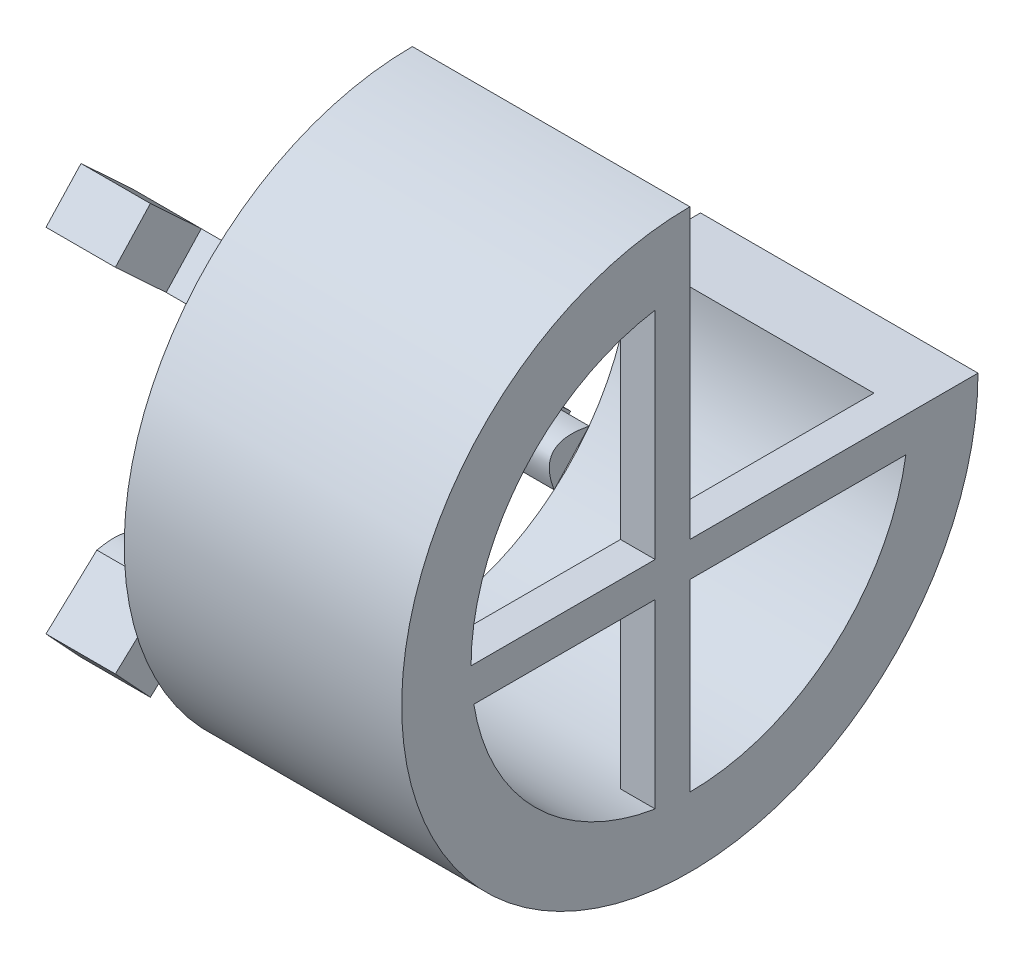
from build123d import *

# Parameters (mm, degrees)
SKETCH1_W             = 20
SKETCH1_H             = 5
REVOLVE1_ANGLE        = 270
BOSS_EXTRUDE1_DEPTH   = 2.5
BOSS_EXTRUDE2_DEPTH   = 10
BOSS_EXTRUDE2_2_DEPTH = 10
BOSS_EXTRUDE2_3_DEPTH = 10
SKETCH5_W             = 5
SKETCH5_H             = 3.710509324
BOSS_EXTRUDE3_DEPTH   = 5
SKETCH6_W             = 5
SKETCH6_H             = 3.710509324
BOSS_EXTRUDE4_DEPTH   = 5
SKETCH7_W             = 5
SKETCH7_H             = 3.710509324
BOSS_EXTRUDE5_DEPTH   = 5


with BuildPart() as part:
    # Sketch1 → Revolve1 (revolve)
    with BuildSketch(Plane.XY):
        with Locations((10, 18.27)):
            Rectangle(SKETCH1_W, SKETCH1_H)
    revolve(axis=Axis((-37.288540606, 0, 0), (1, 0, 0)), revolution_arc=REVOLVE1_ANGLE)

    # Sketch2 → Boss-Extrude1 (add)
    with BuildSketch(Plane(origin=(20, 0, 0), x_dir=(0, 0, -1), z_dir=(1, 0, 0))):
        with BuildLine():
            Line((0, 20.77), (0, -20.77))
            ThreePointArc((0, -20.77), (-1.252278215, -20.732214047), (-2.5, -20.618993671))
            Line((-2.5, -20.618993671), (-2.5, 20.618993671))
            ThreePointArc((-2.5, 20.618993671), (-1.252278215, 20.732214047), (0, 20.77))
        make_face()
        with BuildLine():
            Line((20.77, 0), (-20.77, 0))
            ThreePointArc((-20.77, 0), (-20.732214047, -1.252278215), (-20.618993671, -2.5))
            Line((-20.618993671, -2.5), (20.618993671, -2.5))
            ThreePointArc((20.618993671, -2.5), (20.732214047, -1.252278215), (20.77, 0))
        make_face()
    extrude(amount=-BOSS_EXTRUDE1_DEPTH)


with BuildPart() as body_2:
    # Sketch4 → Boss-Extrude2 (new body)
    with BuildSketch(Plane(origin=(0, 0, 0), x_dir=(0, 0, -1), z_dir=(1, 0, 0))):
        with BuildLine():
            add(Edge.make_bspline(
                [(-12.742278752, 9.291244923), (-8.866010194, 8.493718612), (-10.218618517, 12.011358608)],
                knots=[0, 0, 0, 1, 1, 1], degree=2))
            add(Edge.make_bspline(
                [(-10.218618517, 12.011358608), (-12.742278752, 9.291244923)],
                knots=[0, 0, 1, 1], degree=1))
        make_face()
    extrude(amount=-BOSS_EXTRUDE2_DEPTH)

    # Sketch7 → Boss-Extrude5 (add)
    with BuildSketch(Plane(origin=(0, 10.651301765, 11.480448634), x_dir=(1, 0, 0), z_dir=(0, 0.680138497, 0.733083641))):
        with Locations((-7.5, 0)):
            Rectangle(SKETCH7_W, SKETCH7_H)
    extrude(amount=BOSS_EXTRUDE5_DEPTH)


with BuildPart() as body_3:
    # Sketch4 → Boss-Extrude2 2 (new body)
    with BuildSketch(Plane(origin=(0, 0, 0), x_dir=(0, 0, -1), z_dir=(1, 0, 0))):
        with BuildLine():
            add(Edge.make_bspline(
                [(-12.742278752, -9.291244923), (-8.866010194, -8.493718612), (-10.218618517, -12.011358608)],
                knots=[0, 0, 0, 1, 1, 1], degree=2))
            add(Edge.make_bspline(
                [(-10.218618517, -12.011358608), (-12.742278752, -9.291244923)],
                knots=[0, 0, 1, 1], degree=1))
        make_face()
    extrude(amount=-BOSS_EXTRUDE2_2_DEPTH)

    # Sketch6 → Boss-Extrude4 (add)
    with BuildSketch(Plane(origin=(0, -10.651301765, 11.480448634), x_dir=(1, 0, 0), z_dir=(0, -0.680138497, 0.733083641))):
        with Locations((-7.5, 0)):
            Rectangle(SKETCH6_W, SKETCH6_H)
    extrude(amount=BOSS_EXTRUDE4_DEPTH)


with BuildPart() as body_4:
    # Sketch4 → Boss-Extrude2 3 (new body)
    with BuildSketch(Plane(origin=(0, 0, 0), x_dir=(0, 0, -1), z_dir=(1, 0, 0))):
        with BuildLine():
            add(Edge.make_bspline(
                [(12.742278752, -9.291244923), (8.866010194, -8.493718612), (10.218618517, -12.011358608)],
                knots=[0, 0, 0, 1, 1, 1], degree=2))
            add(Edge.make_bspline(
                [(10.218618517, -12.011358608), (12.742278752, -9.291244923)],
                knots=[0, 0, 1, 1], degree=1))
        make_face()
    extrude(amount=-BOSS_EXTRUDE2_3_DEPTH)

    # Sketch5 → Boss-Extrude3 (add)
    with BuildSketch(Plane(origin=(0, -10.651301765, -11.480448634), x_dir=(-1, 0, 0), z_dir=(0, -0.680138497, -0.733083641))):
        with Locations((7.5, 0)):
            Rectangle(SKETCH5_W, SKETCH5_H)
    extrude(amount=BOSS_EXTRUDE3_DEPTH)


solid = Compound([part.part, body_2.part, body_3.part, body_4.part])
